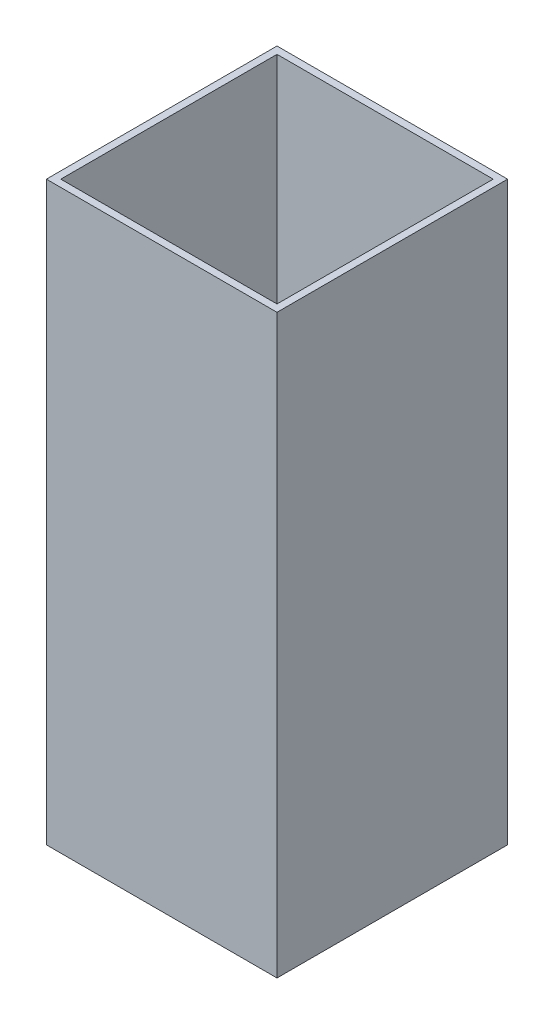
from build123d import *

# Parameters (mm, degrees)
SKETCH1_W           = 32
SKETCH1_H           = 32
SKETCH1_W_2         = 30
SKETCH1_H_2         = 30
BOSS_EXTRUDE1_DEPTH = 40


with BuildPart() as part:
    # Sketch1 → Boss-Extrude1 (new body, symmetric)
    with BuildSketch(Plane(origin=(0, 0, 0), x_dir=(1, 0, 0), z_dir=(0, 1, 0))):
        Rectangle(SKETCH1_W, SKETCH1_H)
        Rectangle(SKETCH1_W_2, SKETCH1_H_2, mode=Mode.SUBTRACT)
    extrude(amount=BOSS_EXTRUDE1_DEPTH, both=True)


solid = part.part
